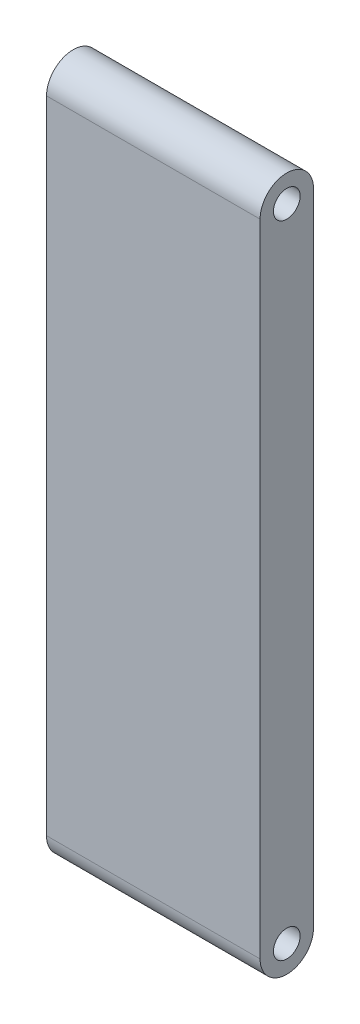
from build123d import *

# Parameters (mm, degrees)
SKETCH1_W           = 20
SKETCH1_H           = 60
BOSS_EXTRUDE1_DEPTH = 5
SKETCH2_R           = 2.5
SKETCH2_R_2         = 1.25
BOSS_EXTRUDE2_DEPTH = 20
SKETCH3_R           = 1.25
CUT_EXTRUDE1_DEPTH  = 29
SKETCH4_R           = 2.5
SKETCH4_R_2         = 1.25
BOSS_EXTRUDE3_DEPTH = 20
SKETCH5_R           = 1.25
CUT_EXTRUDE2_DEPTH  = 29


with BuildPart() as part:
    # Sketch1 → Boss-Extrude1 (new body)
    with BuildSketch(Plane.XY):
        with Locations((10, 30)):
            Rectangle(SKETCH1_W, SKETCH1_H)
    extrude(amount=BOSS_EXTRUDE1_DEPTH)

    # Sketch2 → Boss-Extrude2 (add)
    with BuildSketch(Plane(origin=(20, 0, 0), x_dir=(0, 0, -1), z_dir=(1, 0, 0))):
        with Locations((-2.5, 60)):
            Circle(SKETCH2_R)
        with Locations((-2.5, 60)):
            Circle(SKETCH2_R_2, mode=Mode.SUBTRACT)
    extrude(amount=-BOSS_EXTRUDE2_DEPTH)

    # Sketch3 → Cut-Extrude1 (cut)
    with BuildSketch(Plane.ZY):
        with Locations((2.5, 60)):
            Circle(SKETCH3_R)
    extrude(amount=-CUT_EXTRUDE1_DEPTH, mode=Mode.SUBTRACT)

    # Sketch4 → Boss-Extrude3 (add)
    with BuildSketch(Plane.ZY):
        with Locations((2.5, 0)):
            Circle(SKETCH4_R)
        with Locations((2.5, 0)):
            Circle(SKETCH4_R_2, mode=Mode.SUBTRACT)
    extrude(amount=-BOSS_EXTRUDE3_DEPTH)

    # Sketch5 → Cut-Extrude2 (cut)
    with BuildSketch(Plane(origin=(20, 0, 0), x_dir=(0, 0, -1), z_dir=(1, 0, 0))):
        with Locations((-2.5, 0)):
            Circle(SKETCH5_R)
    extrude(amount=-CUT_EXTRUDE2_DEPTH, mode=Mode.SUBTRACT)


solid = part.part
